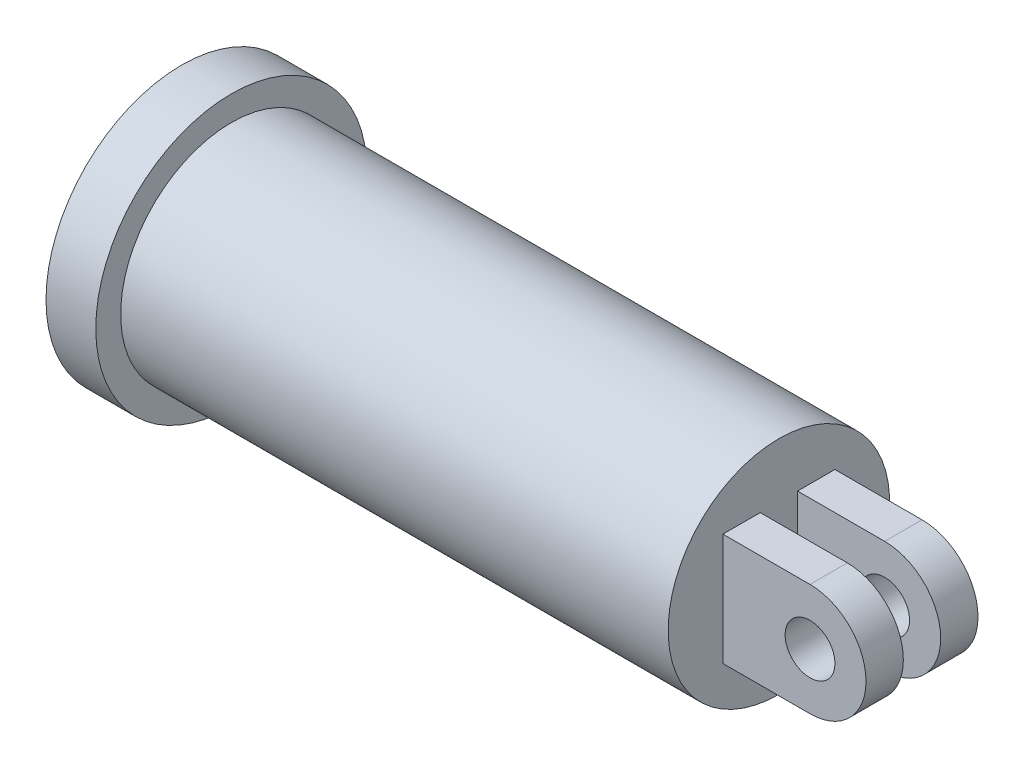
from build123d import *

# Parameters (mm, degrees)
SKETCH3_R           = 10
BOSS_EXTRUDE1_DEPTH = 15


with BuildPart() as part:
    # Sketch2 → Revolve1 (revolve)
    with BuildSketch(Plane.XY):
        Polygon((-120, 0), (120, 0), (120, 44.5), (-100, 44.5), (-100, 54.5), (-120, 54.5), align=None)
    revolve(axis=Axis((-120, 0, 0), (1, 0, 0)))

    # Sketch3 → Boss-Extrude1 (add)
    with BuildSketch(Plane.XY.offset(7.5)):
        with BuildLine():
            Line((120, 22.5), (155, 22.5))
            ThreePointArc((155, 22.5), (177.5, 0), (155, -22.5))
            Line((155, -22.5), (120, -22.5))
            Line((120, -22.5), (120, 22.5))
        make_face()
        with Locations((155, 0)):
            Circle(SKETCH3_R, mode=Mode.SUBTRACT)
    boss_extrude1 = extrude(amount=BOSS_EXTRUDE1_DEPTH)

    # Mirror1: Boss-Extrude1 across plane
    add(boss_extrude1.mirror(Plane.XY))


solid = part.part
